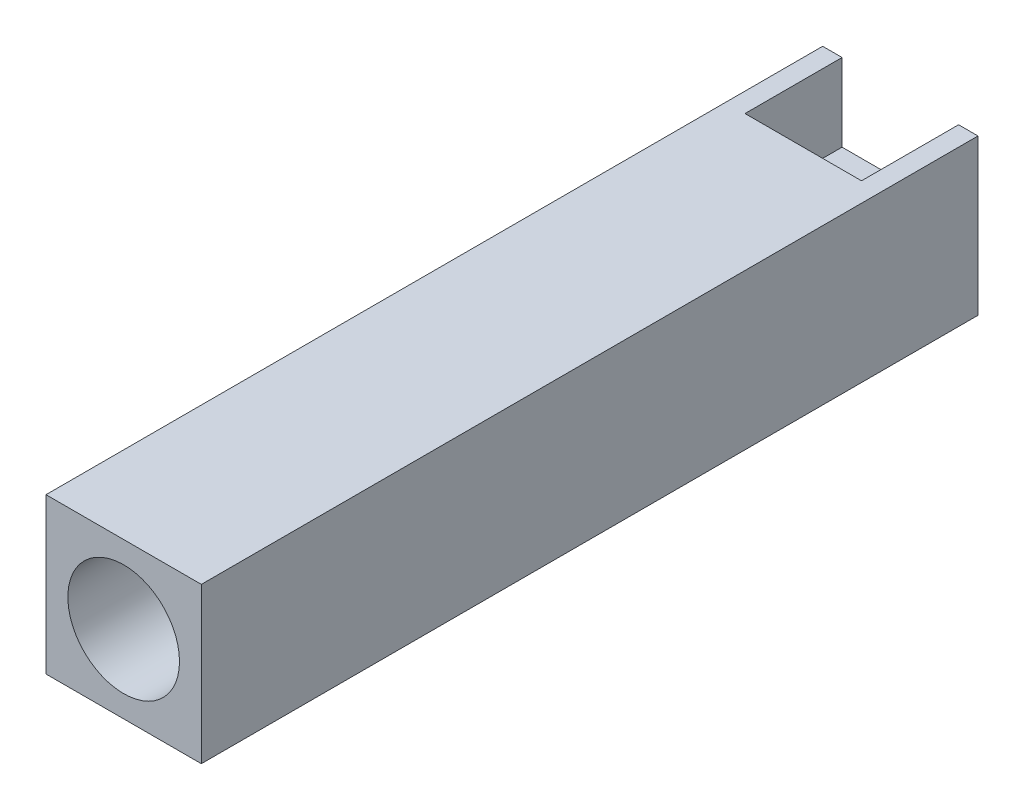
from build123d import *

# Parameters (mm, degrees)
SKETCH_1_W             = 16
SKETCH_1_H             = 16
EXTRUDE_1_DEPTH        = 80
SKETCH_2_R             = 5.75
CUT_EXTRUDE_1_DEPTH    = 50
SKETCH_10_W            = 12
SKETCH_10_H            = 8
SKETCH_10_H_2          = 3
CUT_EXTRUDE_2_DEPTH    = 10
SKETCH_11_R            = 3.25
CUT_EXTRUDE_5_DEPTH    = 1
HOLE_WIZARD_M4_1_D     = 3.3
HOLE_WIZARD_M4_1_DEPTH = 4


with BuildPart() as part:
    # 草图1 → 凸台-拉伸1 (new body)
    with BuildSketch(Plane.XY):
        with Locations((8, -8)):
            Rectangle(SKETCH_1_W, SKETCH_1_H)
    extrude(amount=EXTRUDE_1_DEPTH)

    # 草图2 → 切除-拉伸1 (cut)
    with BuildSketch(Plane.XY.offset(80)):
        with Locations((8, -8)):
            Circle(SKETCH_2_R)
    extrude(amount=-CUT_EXTRUDE_1_DEPTH, mode=Mode.SUBTRACT)

    # 草图10 → 切除-拉伸2 (cut)
    with BuildSketch(Plane(origin=(0, 0, 0), x_dir=(-1, 0, 0), z_dir=(0, 0, -1))):
        with Locations((-8, -4)):
            Rectangle(SKETCH_10_W, SKETCH_10_H)
        with Locations((-8, -14.5)):
            Rectangle(SKETCH_10_W, SKETCH_10_H_2)
    extrude(amount=-CUT_EXTRUDE_2_DEPTH, mode=Mode.SUBTRACT)

    # 草图11 → 切除-拉伸5 (cut)
    with BuildSketch(Plane.XZ.offset(13)):
        with Locations((8, 5)):
            Circle(SKETCH_11_R)
    extrude(amount=-CUT_EXTRUDE_5_DEPTH, mode=Mode.SUBTRACT)

    # M4 螺纹孔的螺纹孔钻头1
    with Locations(Plane(origin=(0, -12, 0), x_dir=(-1, 0, 0), z_dir=(0, -1, 0))):
        with Locations((-8, -5)):
            Hole(HOLE_WIZARD_M4_1_D / 2, depth=HOLE_WIZARD_M4_1_DEPTH)


solid = part.part
